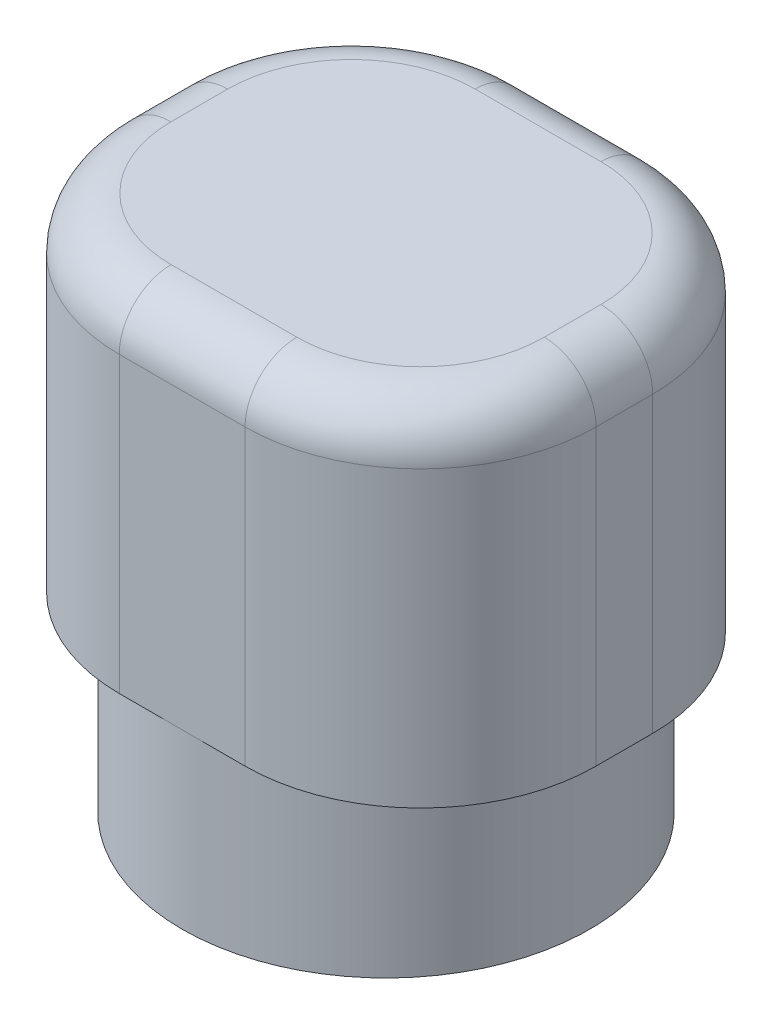
from build123d import *

# Parameters (mm, degrees)
SKETCH1_R           = 2.95
BOSS_EXTRUDE1_DEPTH = 2.5
SKETCH2_R           = 1.75
CUT_EXTRUDE1_DEPTH  = 2.5
SKETCH3_W           = 6.9
SKETCH3_H           = 5.9
BOSS_EXTRUDE2_DEPTH = 5
FILLET1_R           = 2.54
FILLET2_R           = 0.75


with BuildPart() as part:
    # Sketch1 → Boss-Extrude1 (new body)
    with BuildSketch(Plane(origin=(0, 0, 0), x_dir=(1, 0, 0), z_dir=(0, 1, 0))):
        Circle(SKETCH1_R)
    extrude(amount=BOSS_EXTRUDE1_DEPTH)

    # Sketch2 → Cut-Extrude1 (cut)
    with BuildSketch(Plane.XZ):
        Circle(SKETCH2_R)
    extrude(amount=-CUT_EXTRUDE1_DEPTH, mode=Mode.SUBTRACT)

    # Sketch3 → Boss-Extrude2 (add)
    with BuildSketch(Plane(origin=(0, 2.5, 0), x_dir=(1, 0, 0), z_dir=(0, 1, 0))):
        Rectangle(SKETCH3_W, SKETCH3_H)
    extrude(amount=BOSS_EXTRUDE2_DEPTH)

    # Fillet1
    fillet1_edges = [part.edges().sort_by_distance(p)[0] for p in [
        (3.45, 5, 2.95),
        (3.45, 5, -2.95),
        (-3.45, 5, -2.95),
        (-3.45, 5, 2.95),
    ]]
    fillet(fillet1_edges, radius=FILLET1_R)

    # Fillet2
    fillet2_edges = [part.edges().sort_by_distance(p)[0] for p in [
        (-3.45, 7.5, 0),
        (0, 7.5, -2.95),
        (3.45, 7.5, 0),
        (0, 7.5, 2.95),
        (-2.706051224, 7.5, 2.206051224),
        (2.706051224, 7.5, 2.206051224),
        (2.706051224, 7.5, -2.206051224),
        (-2.706051224, 7.5, -2.206051224),
    ]]
    fillet(fillet2_edges, radius=FILLET2_R)


solid = part.part
